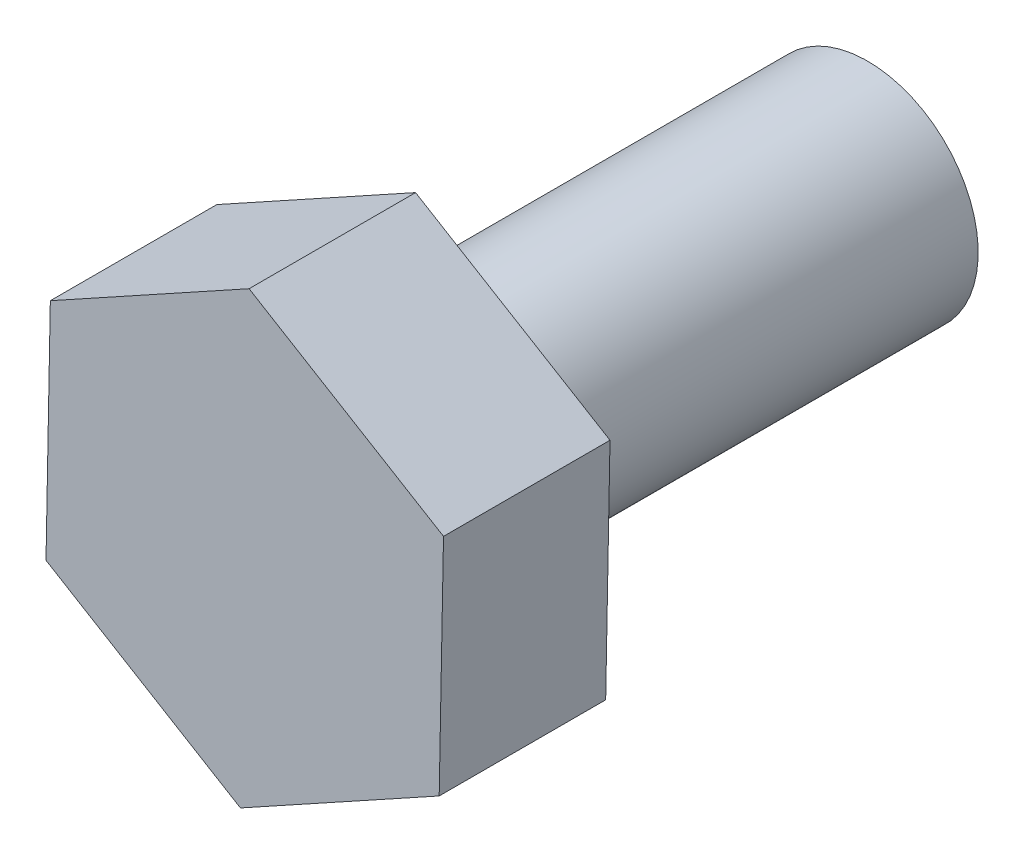
from build123d import *

# Parameters (mm, degrees)
EXTRUDE_1_DEPTH = 2.9
SKETCH_4_R      = 1.925
EXTRUDE_2_DEPTH = 7.95


with BuildPart() as part:
    # Эскиз1 → Бобышка-Вытянуть1 (new body)
    with BuildSketch(Plane.XY):
        Polygon((3.380947783, -1.962353809), (3.456334009, 1.991776974), (0.069649414, 4.034128753), (-3.392421407, 2.122349748), (-3.467807633, -1.831781035), (-0.081123038, -3.874132814), align=None)
    extrude(amount=-EXTRUDE_1_DEPTH)

    # Эскиз4 → Бобышка-Вытянуть2 (add)
    with BuildSketch(Plane(origin=(0, 0, -2.9), x_dir=(-1, 0, 0), z_dir=(0, 0, -1))):
        with Locations((0.005736812, 0.07999797)):
            Circle(SKETCH_4_R)
    extrude(amount=EXTRUDE_2_DEPTH)


solid = part.part
